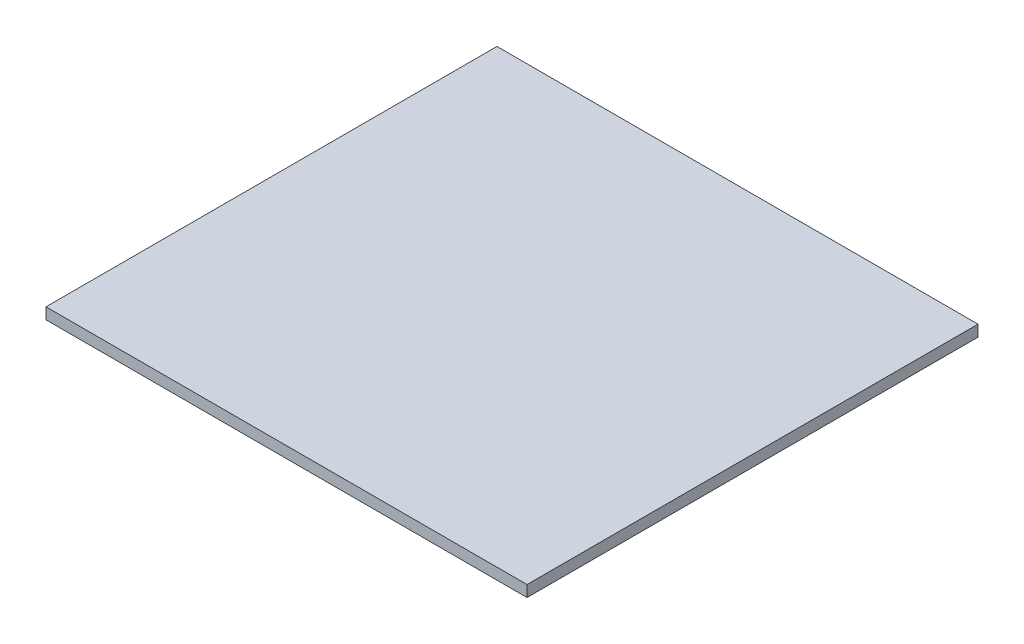
from build123d import *

# Parameters (mm, degrees)
SKETCH1_W           = 203.2
SKETCH1_H           = 190.5
BOSS_EXTRUDE1_DEPTH = 4.7625


with BuildPart() as part:
    # Sketch1 → Boss-Extrude1 (new body)
    with BuildSketch(Plane(origin=(0, 0, 0), x_dir=(1, 0, 0), z_dir=(0, 1, 0))):
        with Locations((101.6, -95.25)):
            Rectangle(SKETCH1_W, SKETCH1_H)
    extrude(amount=BOSS_EXTRUDE1_DEPTH)


solid = part.part
